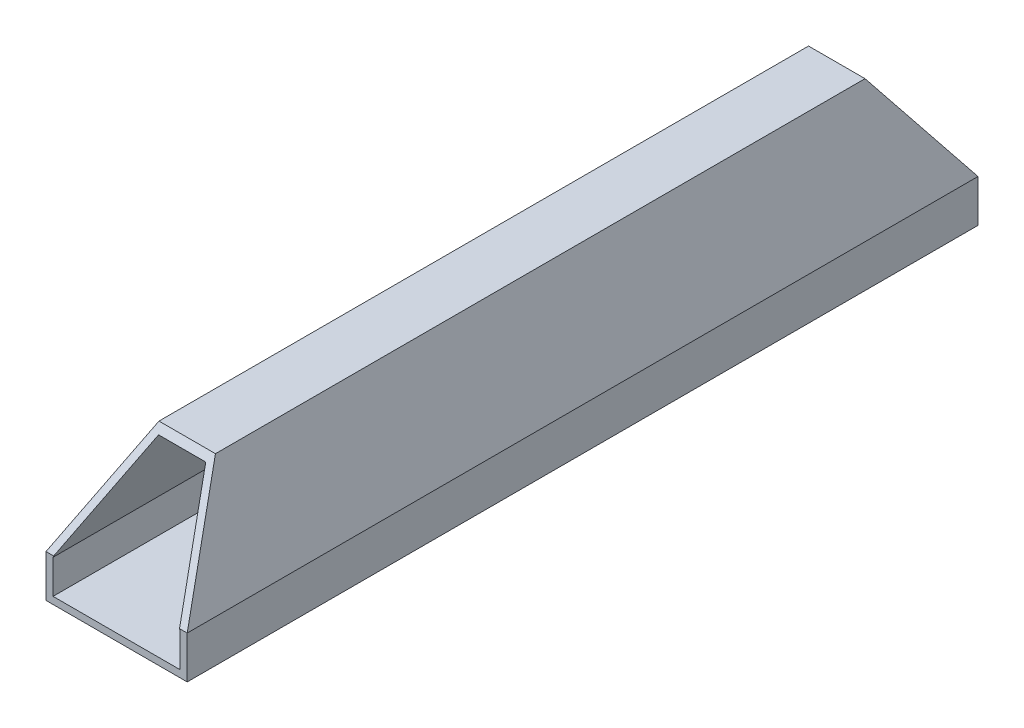
from build123d import *

# Parameters (mm, degrees)
BOSS_EXTRUDE1_DEPTH = 112
CUT_EXTRUDE1_DEPTH  = 113
CUT_EXTRUDE2_DEPTH  = 21
CUT_EXTRUDE3_DEPTH  = 21


with BuildPart() as part:
    # Sketch1 → Boss-Extrude1 (new body)
    with BuildSketch(Plane.XY):
        Polygon((-4, 14), (4, 14), (10, 0), (10, -6), (-10, -6), (-10, 0), align=None)
    extrude(amount=BOSS_EXTRUDE1_DEPTH)

    # Sketch2 → Cut-Extrude1 (cut, through all)
    with BuildSketch(Plane.XY.offset(112)):
        Polygon((-3.340603842, 13), (-9, -0.205257702), (-9, -5), (9, -5), (9, -0.205257702), (3.340603842, 13), align=None)
    extrude(amount=-CUT_EXTRUDE1_DEPTH, mode=Mode.SUBTRACT)

    # Sketch4 → Cut-Extrude2 (cut, through all)
    with BuildSketch(Plane(origin=(10, 0, 0), x_dir=(0, 0, -1), z_dir=(1, 0, 0))):
        Polygon((-112, 14), (-102, 14), (-112, 0), align=None)
    extrude(amount=-CUT_EXTRUDE2_DEPTH, mode=Mode.SUBTRACT)

    # Sketch5 → Cut-Extrude3 (cut, through all)
    with BuildSketch(Plane.ZY.offset(10)):
        Polygon((0, 14), (10, 14), (0, 0), align=None)
    extrude(amount=-CUT_EXTRUDE3_DEPTH, mode=Mode.SUBTRACT)


solid = part.part
